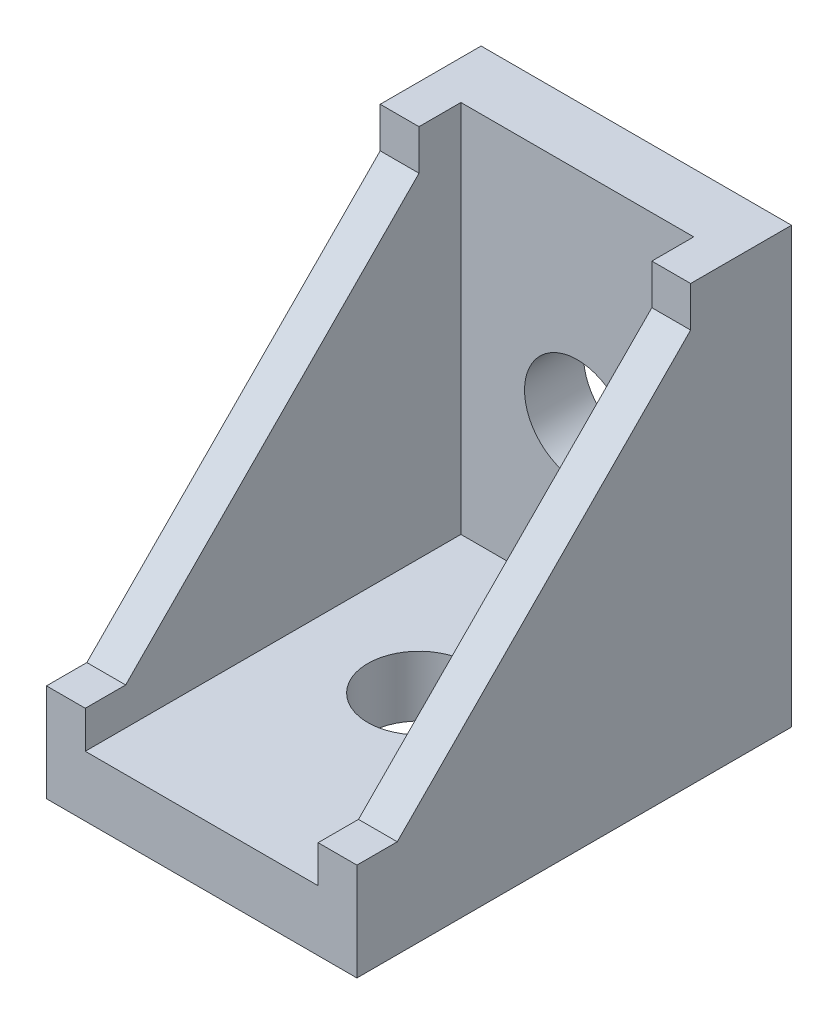
from build123d import *

# Parameters (mm, degrees)
SKETCH1_W           = 20
SKETCH1_H           = 28
SKETCH1_R           = 3.4
BOSS_EXTRUDE1_DEPTH = 3.8
SKETCH2_W           = 20
SKETCH2_H           = 28
SKETCH2_R           = 3.3
BOSS_EXTRUDE2_DEPTH = 3.9
SKETCH3_W           = 6.5
SKETCH3_H           = 24.1
BOSS_EXTRUDE3_DEPTH = 2.5
SKETCH4_W           = 28
SKETCH4_H           = 6.3
BOSS_EXTRUDE4_DEPTH = 2.5
BOSS_EXTRUDE5_DEPTH = 2.5


with BuildPart() as part:
    # Sketch1 → Boss-Extrude1 (new body)
    with BuildSketch(Plane.XY):
        Rectangle(SKETCH1_W, SKETCH1_H)
        Circle(SKETCH1_R, mode=Mode.SUBTRACT)
    extrude(amount=BOSS_EXTRUDE1_DEPTH)

    # Sketch2 → Boss-Extrude2 (add)
    with BuildSketch(Plane.XZ.offset(14)):
        with Locations((0, 14)):
            Rectangle(SKETCH2_W, SKETCH2_H)
        with Locations((0, 14)):
            Circle(SKETCH2_R, mode=Mode.SUBTRACT)
    extrude(amount=-BOSS_EXTRUDE2_DEPTH)

    # Sketch3 → Boss-Extrude3 (add)
    with BuildSketch(Plane.ZY.offset(10)):
        with Locations((3.25, 1.95)):
            Rectangle(SKETCH3_W, SKETCH3_H)
    boss_extrude3 = extrude(amount=-BOSS_EXTRUDE3_DEPTH)

    # Mirror1: Boss-Extrude3 across plane
    add(boss_extrude3.mirror(Plane(origin=(0, 0, 0), x_dir=(0, 0, 1), z_dir=(1, 0, 0))))

    # Sketch4 → Boss-Extrude4 (add)
    with BuildSketch(Plane.ZY.offset(10)):
        with Locations((14, -10.85)):
            Rectangle(SKETCH4_W, SKETCH4_H)
    boss_extrude4 = extrude(amount=-BOSS_EXTRUDE4_DEPTH)

    # Mirror2: Boss-Extrude4 across plane
    add(boss_extrude4.mirror(Plane(origin=(0, 0, 0), x_dir=(0, 0, 1), z_dir=(1, 0, 0))))

    # Sketch5 → Boss-Extrude5 (add)
    with BuildSketch(Plane.ZY.offset(10)):
        Polygon((6.5, 11.4), (25.4, -7.7), (6.5, -7.7), align=None)
    boss_extrude5 = extrude(amount=-BOSS_EXTRUDE5_DEPTH)

    # Mirror3: Boss-Extrude5 across plane
    add(boss_extrude5.mirror(Plane(origin=(0, 0, 0), x_dir=(0, 0, 1), z_dir=(1, 0, 0))))


solid = part.part
